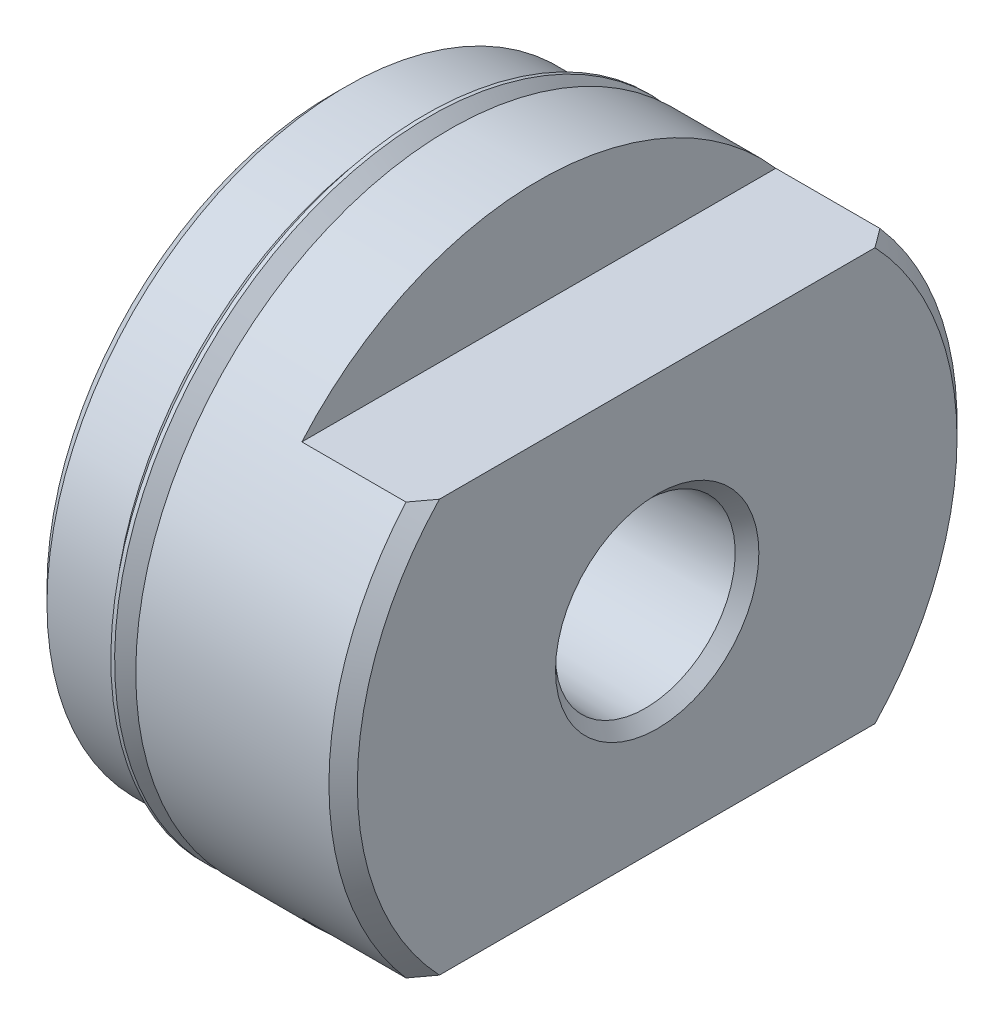
from build123d import *

# Parameters (mm, degrees)
SKETCH3_W          = 134.7724
SKETCH3_H          = 67.3862
SKETCH3_W_2        = 67.3862
SKETCH3_H_2        = 22.1107
CUT_EXTRUDE1_DEPTH = 6.35
SKETCH4_W          = 7.9248
SKETCH4_H          = 11.1125


with BuildPart() as part:
    # Sketch1 → Revolve1 (revolve)
    with BuildSketch(Plane.XY):
        Polygon((0, 0), (0, 15.25905), (0.762, 16.02105), (4.318, 16.02105), (5.334, 15.00505), (6.35, 15.00505), (6.35, 16.84655), (16.7132, 16.84655), (17.4752, 16.08455), (17.4752, 0), align=None)
    revolve(axis=Axis((17.4752, 0, 0), (-1, 0, 0)))

    # Sketch2 → Cut-Revolve1 (revolve, cut)
    with BuildSketch(Plane.XY):
        Polygon((0, 0), (0, 4.3688), (2.398876108, 4.3688), (16.840187191, 4.819651116), (17.4752, 5.454663925), (17.4752, 0), align=None)
    revolve(axis=Axis((17.4752, 0, 0), (-1, 0, 0)), mode=Mode.SUBTRACT)

    # Sketch3 → Cut-Extrude1 (cut)
    with BuildSketch(Plane(origin=(17.4752, 0, 0), x_dir=(0, 0, -1), z_dir=(1, 0, 0))):
        Rectangle(SKETCH3_W, SKETCH3_H)
        Rectangle(SKETCH3_W_2, SKETCH3_H_2, mode=Mode.SUBTRACT)
    extrude(amount=-CUT_EXTRUDE1_DEPTH, mode=Mode.SUBTRACT)

    # Sketch4 → Cut-Revolve2 (revolve, cut)
    with BuildSketch(Plane.XY):
        with Locations((3.9624, 5.55625)):
            Rectangle(SKETCH4_W, SKETCH4_H)
    revolve(axis=Axis((7.9248, 0, 0), (-1, 0, 0)), mode=Mode.SUBTRACT)

    # Sketch5 → Revolve2 (revolve)
    with BuildSketch(Plane.XY):
        with BuildLine():
            Line((5.013509175, 16.762381804), (6.216617928, 15.559273051))
            ThreePointArc((6.216617928, 15.559273051), (6.253815367, 15.46947049), (6.216617928, 15.379667928))
            Line((6.216617928, 15.379667928), (5.842, 15.00505))
            Line((5.842, 15.00505), (5.334, 15.00505))
            Line((5.334, 15.00505), (5.334, 14.75105))
            Line((5.334, 14.75105), (6.35, 14.75105))
            Line((6.35, 14.75105), (6.35, 15.713259175))
            Line((6.35, 15.713259175), (5.216709175, 16.84655))
            Line((5.216709175, 16.84655), (5.013509175, 16.84655))
            Line((5.013509175, 16.84655), (5.013509175, 16.762381804))
        make_face()
    revolve(axis=Axis((6.35, 0, 0), (-1, 0, 0)))


solid = part.part
